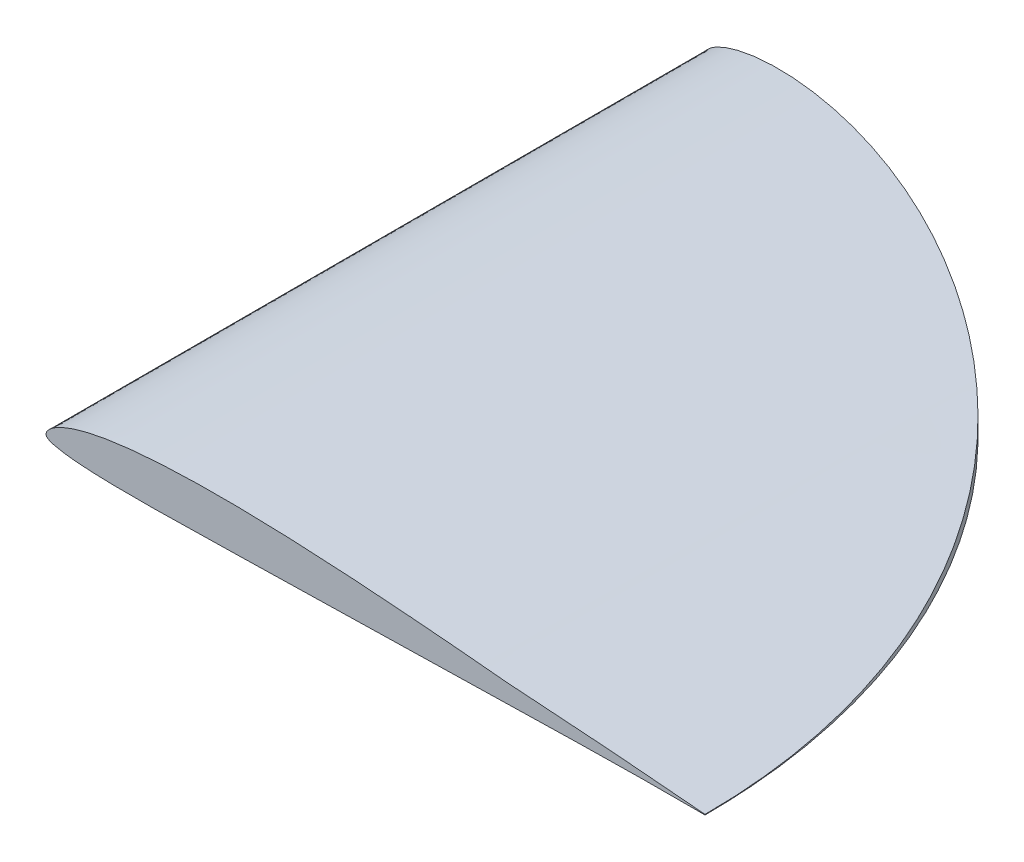
from build123d import *

# Parameters (mm, degrees)
BOSS_EXTRUDE1_DEPTH     = 609.6
CUT_EXTRUDE1_DEPTH      = 863.647681923
CUT_EXTRUDE1_DEPTH_BACK = 863.647681923


with BuildPart() as part:
    # Sketch2 → Boss-Extrude1 (new body)
    with BuildSketch(Plane.XY):
        with BuildLine():
            Line((609.6, 0.2572512), (609.6, -0.2572512))
            add(Edge.make_bspline(
                [(609.6, 0.2572512), (608.415332097, 0.365220961), (604.821920112, 0.692721884), (598.502007136, 1.275206353), (590.58254836, 1.967431913), (582.277507556, 2.69834775), (573.900639024, 3.433908802), (565.499768181, 4.14030961), (557.08903134, 4.846256275), (548.671470775, 5.535789265), (540.251460963, 6.217951202), (531.831087952, 6.885244816), (523.412952246, 7.534822651), (514.997410973, 8.181778582), (506.585239979, 8.808438766), (498.174683562, 9.428123701), (489.768603017, 10.036024513), (481.363733408, 10.627037843), (472.962708832, 11.214922115), (464.562923613, 11.786551917), (456.166431988, 12.347053861), (447.770845571, 12.898278365), (440.003199426, 13.399668731), (433.96438498, 13.774120994), (430.191548537, 14.023076282), (428.055464604, 14.131886527), (425.933843798, 14.359293563), (421.47120443, 14.773485107), (414.671159239, 15.434327135), (407.520357673, 16.101483217), (401.128541792, 16.694213561), (395.401359899, 17.22201905), (388.224784964, 17.873405506), (379.841092841, 18.625086168), (371.28338943, 19.375916411), (362.748078527, 20.110888169), (354.702041793, 20.790978105), (346.78738924, 21.447313902), (339.891559101, 22.005736324), (334.200190675, 22.458547528), (327.939742949, 22.951362128), (320.686038813, 23.505992825), (312.247970741, 24.134130856), (303.815472288, 24.743216311), (292.577471879, 25.524421758), (281.340715435, 26.260729616), (270.106228216, 26.94818818), (261.682346264, 27.436441163), (250.453525202, 28.050663502), (239.225848559, 28.605886591), (227.998808811, 29.09599885), (219.581483994, 29.431362872), (211.166063809, 29.727195505), (202.753122181, 29.985581608), (194.343821157, 30.203485951), (185.938586629, 30.379470231), (177.537558104, 30.507218814), (169.140805594, 30.588495554), (160.749075784, 30.614937204), (152.364629575, 30.585236939), (143.988472876, 30.494909638), (135.622585739, 30.340964124), (127.268221532, 30.115005994), (118.928591145, 29.812494639), (110.60788121, 29.427346901), (102.308841137, 28.949642229), (94.038249233, 28.3746447), (85.801677902, 27.687442171), (77.606678285, 26.880816531), (69.466666809, 25.936133655), (61.393491068, 24.842402689), (53.410773367, 23.577087289), (45.541073, 22.114577537), (37.828810634, 20.426039702), (30.344021962, 18.476124586), (23.224210357, 16.249803841), (16.73361216, 13.768469819), (11.252591229, 11.166192123), (7.074403395, 8.664164182), (4.191987844, 6.471552962), (2.320737094, 4.654116149), (1.130561945, 3.146993807), (0.409689764, 1.865312365), (0.044535005, 0.764440717), (-0.039420771, -0.205149315), (0.170080572, -1.119227224), (0.77169585, -1.997178905), (1.832854324, -2.778631321), (3.371729637, -3.573521318), (5.634111878, -4.43110414), (8.992017444, -5.385225136), (13.744089942, -6.360246924), (19.84399051, -7.269127446), (26.92210705, -8.022274727), (34.545085162, -8.60190488), (42.441760907, -9.031325034), (50.486885076, -9.336056111), (58.626052563, -9.543047104), (66.830678248, -9.67489609), (75.083068743, -9.746684223), (83.37275756, -9.769167554), (91.690844547, -9.745806087), (100.032857577, -9.684772804), (108.393145156, -9.593540277), (116.770051914, -9.474576166), (125.161791998, -9.335610545), (133.570790806, -9.179897921), (141.997089596, -9.012506765), (150.441602227, -8.832092507), (158.904312825, -8.64914415), (167.386853653, -8.456730101), (175.887910278, -8.260841912), (187.252103698, -7.996737324), (198.632675581, -7.727171132), (210.026906928, -7.45830873), (218.585094291, -7.256877402), (227.150559846, -7.053877202), (235.724404509, -6.852705707), (244.307745405, -6.649639518), (252.896010837, -6.449008432), (261.483640787, -6.24829195), (270.065374104, -6.048618778), (278.641674775, -5.85209268), (287.212793757, -5.65257078), (295.778321245, -5.458536237), (304.337492142, -5.264022213), (312.891023844, -5.072759296), (321.44083742, -4.880022295), (328.678634748, -4.71921452), (337.117358168, -4.532427393), (345.442615864, -4.344684062), (354.907090423, -4.135025854), (363.144630539, -3.952222438), (371.410158212, -3.766386754), (379.761491454, -3.581397323), (387.236605751, -3.415807595), (393.781063961, -3.271543457), (399.309746187, -3.151196232), (405.669272764, -3.011720732), (412.973515337, -2.854345409), (419.722986413, -2.708088451), (424.298269937, -2.611697174), (426.517176923, -2.563351102), (428.402740136, -2.527364572), (432.230339127, -2.443039947), (438.456409466, -2.313286096), (446.639671523, -2.142373496), (455.091157591, -1.96841256), (463.538207143, -1.798367427), (471.982967287, -1.628060144), (480.428801943, -1.462530887), (488.87598851, -1.296229127), (497.325250778, -1.135819597), (505.775654302, -0.97821935), (514.228412573, -0.836310375), (525.501397646, -0.657092333), (536.778214476, -0.504290503), (548.056115404, -0.375956926), (556.518004069, -0.29902312), (564.980262271, -0.234734468), (573.44458568, -0.192149035), (581.904839109, -0.170755614), (590.311066301, -0.167311659), (598.338471518, -0.200425886), (604.751458285, -0.229605115), (608.397259937, -0.250393251), (609.6, -0.2572512)],
                knots=[0, 0, 0, 0, 0.002900997, 0.008799492, 0.015477521, 0.022287594, 0.029131106, 0.035984573, 0.042846882, 0.049714298, 0.05658103, 0.063447841, 0.070313229, 0.077171168, 0.084031174, 0.090884627, 0.097737396, 0.104584409, 0.111431996, 0.118274877, 0.125116136, 0.131953905, 0.138793041, 0.144098463, 0.146708547, 0.148014316, 0.149313147, 0.151910856, 0.158944662, 0.165973894, 0.169425198, 0.174599098, 0.179999827, 0.186998484, 0.195126222, 0.200949457, 0.207890371, 0.214817866, 0.220316978, 0.224762114, 0.228741132, 0.235631413, 0.242503169, 0.249375779, 0.256249105, 0.269975124, 0.276837254, 0.283697593, 0.290552693, 0.304261607, 0.311111523, 0.317957829, 0.324804965, 0.331646618, 0.338483878, 0.345319338, 0.352148661, 0.358973535, 0.365797142, 0.372613328, 0.379420455, 0.386224885, 0.393018255, 0.399801226, 0.406575621, 0.413331117, 0.420072962, 0.426793048, 0.433486562, 0.440153627, 0.446776036, 0.453352888, 0.45986197, 0.466293612, 0.472602109, 0.478718386, 0.484476601, 0.489534097, 0.493495639, 0.496331131, 0.498346313, 0.499841011, 0.500999224, 0.501914653, 0.502649229, 0.503345398, 0.504157805, 0.50518516, 0.50652574, 0.508375842, 0.511073875, 0.515031357, 0.520196697, 0.526108615, 0.532386125, 0.538838474, 0.545393385, 0.552018993, 0.558693317, 0.565404176, 0.572144526, 0.578909155, 0.585689295, 0.592488493, 0.599298368, 0.606119897, 0.612956027, 0.619808707, 0.626672964, 0.633554162, 0.640451345, 0.647364459, 0.654290996, 0.668172424, 0.675125782, 0.68208558, 0.689048858, 0.69602005, 0.703000172, 0.70998671, 0.716969769, 0.723948347, 0.730920449, 0.737890086, 0.744856199, 0.751814362, 0.758768528, 0.765720713, 0.772669892, 0.776423534, 0.786305074, 0.792977667, 0.799509992, 0.806398719, 0.813139713, 0.819881191, 0.82463258, 0.829103409, 0.833367055, 0.84014514, 0.846920231, 0.849830697, 0.851305256, 0.85233271, 0.85442981, 0.86064179, 0.867519383, 0.874390494, 0.8812566, 0.888123181, 0.894988723, 0.901857217, 0.908727131, 0.915597457, 0.922468599, 0.929343575, 0.943092095, 0.949971604, 0.956848493, 0.963728748, 0.970608901, 0.977490477, 0.984360632, 0.991108924, 0.997066858, 1, 1, 1, 1], degree=3))
        make_face()
    extrude(amount=-BOSS_EXTRUDE1_DEPTH)

    # Sketch3 → Cut-Extrude1 (cut, two sides: drawn at the far end of the back side and taken through both)
    with BuildSketch(Plane(origin=(0, 0, 0), x_dir=(1, 0, 0), z_dir=(0, 1, 0)).offset(-CUT_EXTRUDE1_DEPTH_BACK)):
        with BuildLine():
            ThreePointArc((609.6, 0), (431.052293811, 431.052293811), (0, 609.6))
            Line((0, 609.6), (609.6, 609.6))
            Line((609.6, 609.6), (609.6, 0))
        make_face()
    extrude(amount=CUT_EXTRUDE1_DEPTH + CUT_EXTRUDE1_DEPTH_BACK, mode=Mode.SUBTRACT)


solid = part.part
